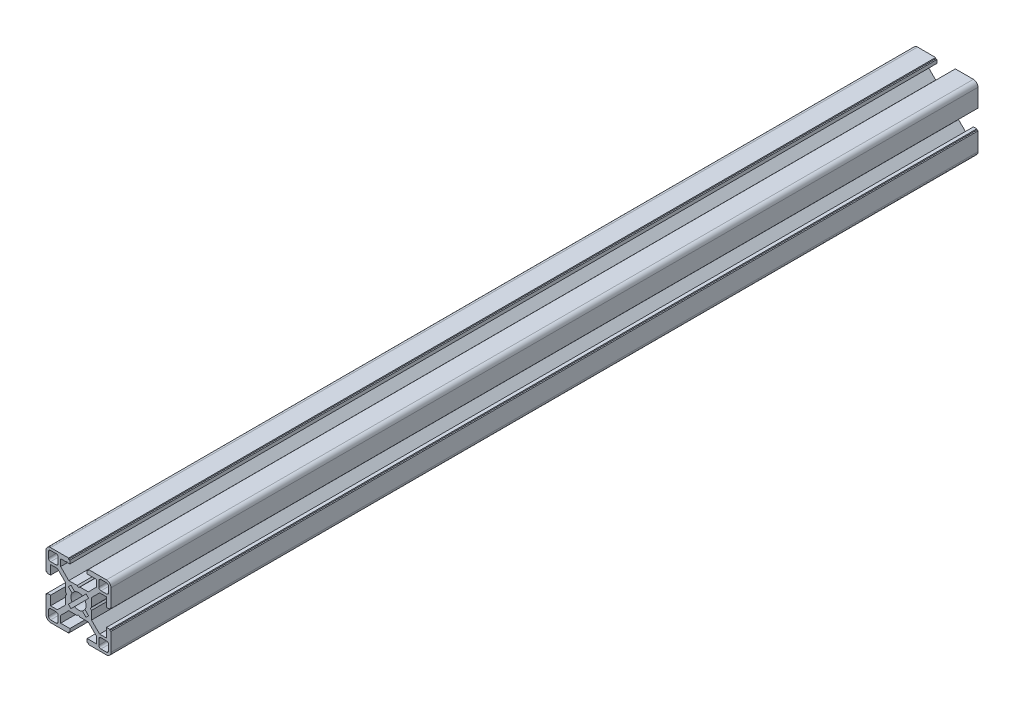
from build123d import *

# Parameters (mm, degrees)
BOSS_EXTRUDE1_DEPTH     = 200
CUT_EXTRUDE1_DEPTH      = 1
CUT_EXTRUDE1_DEPTH_BACK = 401


with BuildPart() as part:
    # Sketch4 → Boss-Extrude1 (new body, symmetric)
    with BuildSketch(Plane.XY):
        with BuildLine():
            Line((0, -5.45), (0.655464476, -6))
            Line((0.655464476, -6), (4.504469158, -6))
            Line((4.504469158, -6), (8.25, -9.745530842))
            Line((8.25, -9.745530842), (8.25, -12.885))
            Line((8.25, -12.885), (4, -12.885))
            Line((4, -12.885), (4, -14.45))
            Line((4, -14.45), (4.55, -14.45))
            Line((4.55, -14.45), (4.55, -15))
            Line((4.55, -15), (12.885, -15))
            ThreePointArc((12.885, -15), (14.380530842, -14.380530842), (15, -12.885))
            Line((15, -12.885), (15, -4.55))
            Line((15, -4.55), (14.45, -4.55))
            Line((14.45, -4.55), (14.45, -4))
            Line((14.45, -4), (12.885, -4))
            Line((12.885, -4), (12.885, -8.25))
            Line((12.885, -8.25), (9.745530842, -8.25))
            Line((9.745530842, -8.25), (6, -4.504469158))
            Line((6, -4.504469158), (6, -0.655464476))
            Line((6, -0.655464476), (5.45, 0))
            Line((5.45, 0), (3.5, 0))
            ThreePointArc((3.5, 0), (3.371433308, -0.939913534), (2.995178599, -1.81077474))
            Line((2.995178599, -1.81077474), (4.675743591, -3.491339732))
            Line((4.675743591, -3.491339732), (3.491339732, -4.675743591))
            Line((3.491339732, -4.675743591), (1.81077474, -2.995178599))
            ThreePointArc((1.81077474, -2.995178599), (0.939913534, -3.371433308), (0, -3.5))
            Line((0, -3.5), (0, -5.45))
        make_face()
        with BuildLine():
            Line((9.375, -10.365), (9.375, -12.885))
            ThreePointArc((9.375, -12.885), (9.664964287, -13.585035713), (10.365, -13.875))
            Line((10.365, -13.875), (12.885, -13.875))
            ThreePointArc((12.885, -13.875), (13.585035713, -13.585035713), (13.875, -12.885))
            Line((13.875, -12.885), (13.875, -10.365))
            ThreePointArc((13.875, -10.365), (13.585035713, -9.664964287), (12.885, -9.375))
            Line((12.885, -9.375), (10.365, -9.375))
            ThreePointArc((10.365, -9.375), (9.664964287, -9.664964287), (9.375, -10.365))
        make_face(mode=Mode.SUBTRACT)
    extrude(amount=BOSS_EXTRUDE1_DEPTH, both=True)

    # Mirror1: part across plane


with BuildPart() as part_1:
    add(part.part)
    add(part.part.mirror(Plane(origin=(0, 0, 0), x_dir=(0, 0, 1), z_dir=(1, 0, 0))))

    # Mirror2: part across plane


with BuildPart() as part_2:
    add(part_1.part)
    add(part_1.part.mirror(Plane.ZX))

    # Sketch5 → Cut-Extrude1 (cut, two sides)
    with BuildSketch(Plane.XY.offset(200)) as cut_extrude1_sk:
        Polygon((-5.675, 12.885), (-5.4, 13.16), (-5.125, 12.885), align=None)
    extrude(amount=CUT_EXTRUDE1_DEPTH, mode=Mode.SUBTRACT)
    extrude(cut_extrude1_sk.sketch, amount=-CUT_EXTRUDE1_DEPTH_BACK, mode=Mode.SUBTRACT)


solid = part_2.part
